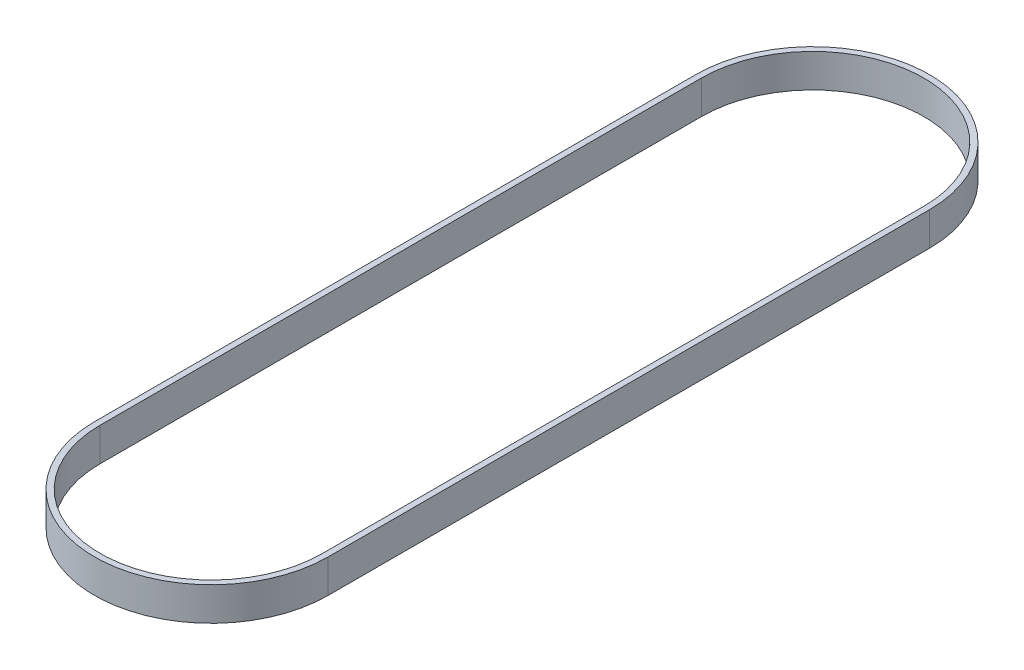
from build123d import *

# Parameters (mm, degrees)
EXTRUDE_1_DEPTH = 10


with BuildPart() as part:
    # 草图1 → 凸台-拉伸1 (new body)
    with BuildSketch(Plane(origin=(0, 0, 0), x_dir=(1, 0, 0), z_dir=(0, 1, 0))):
        with BuildLine():
            Line((-35, 90), (-35, -90))
            ThreePointArc((-35, -90), (0, -125), (35, -90))
            Line((35, -90), (35, 90))
            ThreePointArc((35, 90), (0, 125), (-35, 90))
        make_face()
        with BuildLine():
            Line((-33.26, 90), (-33.26, -90))
            ThreePointArc((-33.26, -90), (0, -123.26), (33.26, -90))
            Line((33.26, -90), (33.26, 90))
            ThreePointArc((33.26, 90), (0, 123.26), (-33.26, 90))
        make_face(mode=Mode.SUBTRACT)
    extrude(amount=EXTRUDE_1_DEPTH)


solid = part.part
